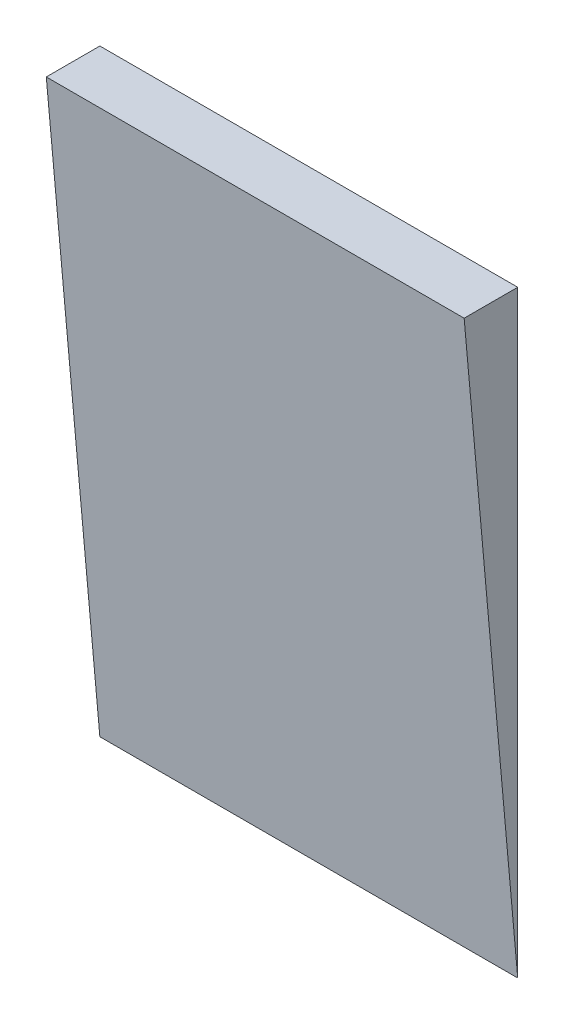
from build123d import *

# Parameters (mm, degrees)
BOSS_EXTRUDE1_DEPTH = 117


with BuildPart() as part:
    # Sketch3 → Boss-Extrude1 (new body)
    with BuildSketch(Plane(origin=(0, 0, 0), x_dir=(0, 0, -1), z_dir=(1, 0, 0))):
        Polygon((-15, 0), (0, -167.497927019), (0, 0), align=None)
    extrude(amount=-BOSS_EXTRUDE1_DEPTH)


solid = part.part
